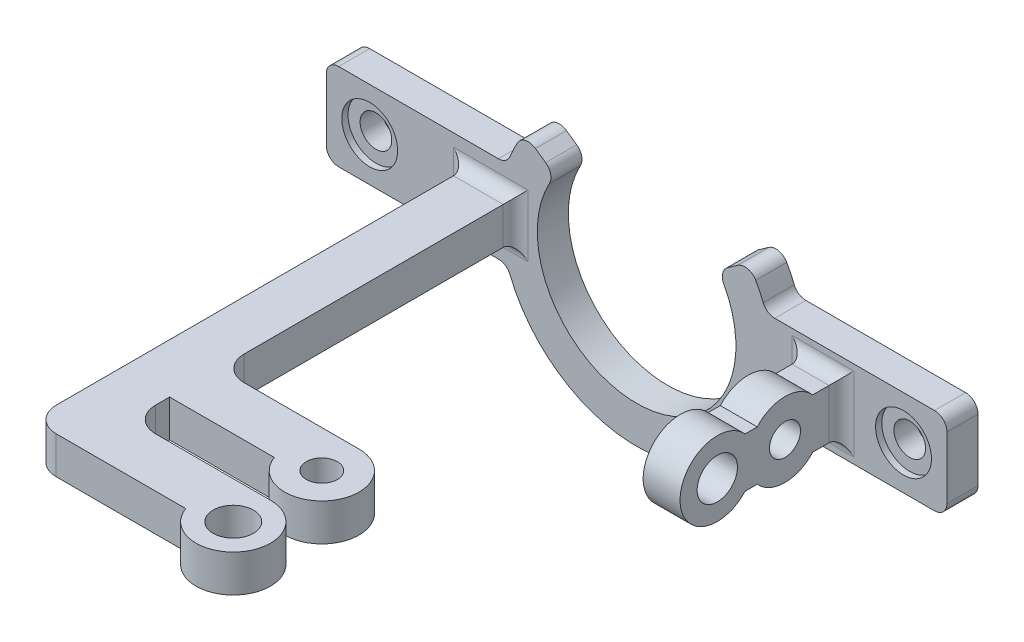
from build123d import *

# Parameters (mm, degrees)
SKETCH1_R                = 2.55
BOSS_EXTRUDE1_DEPTH      = 5
SKETCH4_R                = 4.5
CUT_EXTRUDE2_DEPTH       = 1
SKETCH6_W                = 5.947651005
SKETCH6_H                = 20
BOSS_EXTRUDE2_DEPTH      = 4
BOSS_EXTRUDE2_DEPTH_BACK = 4
SKETCH11_R               = 4.5
CUT_EXTRUDE3_DEPTH       = 0.5
SKETCH16_R               = 3.25
SKETCH16_R_2             = 2.5
BOSS_EXTRUDE3_DEPTH      = 3
BOSS_EXTRUDE3_DEPTH_BACK = 3
FILLET3_R                = 2
BOSS_EXTRUDE4_DEPTH      = 5.947651
CUT_EXTRUDE5_REACH       = 85
SKETCH18_R               = 3.25
SKETCH18_R_2             = 2.5


with BuildPart() as part:
    # Sketch1 → Boss-Extrude1 (new body)
    with BuildSketch(Plane.XY):
        with BuildLine():
            Line((100, 25), (100, 20))
            ThreePointArc((100, 20), (99.414213562, 18.585786438), (98, 18))
            Line((98, 18), (72.248595461, 18))
            ThreePointArc((72.248595461, 18), (71.130561473, 17.658312395), (70.39454584, 16.75))
            ThreePointArc((70.39454584, 16.75), (50, 3), (29.60545416, 16.75))
            ThreePointArc((29.60545416, 16.75), (28.869438527, 17.658312395), (27.751404539, 18))
            Line((27.751404539, 18), (2, 18))
            ThreePointArc((2, 18), (0.585786438, 18.585786438), (0, 20))
            Line((0, 20), (0, 25))
            Line((0, 25), (0, 30))
            ThreePointArc((0, 30), (0.585786438, 31.414213562), (2, 32))
            Line((2, 32), (21.056240945, 32))
            Line((21.056240945, 32), (27.751404539, 32))
            ThreePointArc((27.751404539, 32), (28.869438527, 32.341687605), (29.60545416, 33.25))
            ThreePointArc((29.60545416, 33.25), (30.166752838, 34.520625347), (30.807119991, 35.753295167))
            ThreePointArc((30.807119991, 35.753295167), (32.106461975, 36.725482012), (33.699080137, 36.414026968))
            Line((33.699080137, 36.414026968), (35.34656276, 35.260447216))
            ThreePointArc((35.34656276, 35.260447216), (36.146649881, 34.078494315), (35.955031011, 32.664127224))
            ThreePointArc((35.955031011, 32.664127224), (50, 9), (64.044968989, 32.664127224))
            ThreePointArc((64.044968989, 32.664127224), (63.853350119, 34.078494315), (64.65343724, 35.260447216))
            Line((64.65343724, 35.260447216), (66.300919863, 36.414026968))
            ThreePointArc((66.300919863, 36.414026968), (67.893538025, 36.725482012), (69.192880009, 35.753295167))
            ThreePointArc((69.192880009, 35.753295167), (69.833247162, 34.520625347), (70.39454584, 33.25))
            ThreePointArc((70.39454584, 33.25), (71.130561473, 32.341687605), (72.248595461, 32))
            Line((72.248595461, 32), (78.943759055, 32))
            Line((78.943759055, 32), (98, 32))
            ThreePointArc((98, 32), (99.414213562, 31.414213562), (100, 30))
            Line((100, 30), (100, 25))
        make_face()
        with Locations((93, 25)):
            Circle(SKETCH1_R, mode=Mode.SUBTRACT)
        with Locations((7, 25)):
            Circle(SKETCH1_R, mode=Mode.SUBTRACT)
    extrude(amount=BOSS_EXTRUDE1_DEPTH)

    # Sketch4 → Cut-Extrude2 (cut)
    with BuildSketch(Plane.XY.offset(5)):
        with Locations((93, 25)):
            Circle(SKETCH4_R)
        with Locations((7, 25)):
            Circle(SKETCH4_R)
    extrude(amount=-CUT_EXTRUDE2_DEPTH, mode=Mode.SUBTRACT)

    # Sketch6 → Boss-Extrude2 (add, two sides)
    with BuildSketch(Plane(origin=(0, 25, 0), x_dir=(-1, 0, 0), z_dir=(0, -1, 0))) as boss_extrude2_sk:
        with Locations((-80.026174497, -15)):
            Rectangle(SKETCH6_W, SKETCH6_H)
    extrude(amount=BOSS_EXTRUDE2_DEPTH)
    extrude(boss_extrude2_sk.sketch, amount=-BOSS_EXTRUDE2_DEPTH_BACK)

    # Sketch11 → Cut-Extrude3 (cut)
    with BuildSketch(Plane(origin=(0, 0, 0), x_dir=(-1, 0, 0), z_dir=(0, 0, -1))):
        with Locations((-93, 25)):
            Circle(SKETCH11_R)
        with Locations((-7, 25)):
            Circle(SKETCH11_R)
    extrude(amount=-CUT_EXTRUDE3_DEPTH, mode=Mode.SUBTRACT)

    # Sketch16 → Boss-Extrude3 (add, two sides)
    with BuildSketch(Plane(origin=(0, 25, 0), x_dir=(-1, 0, 0), z_dir=(0, -1, 0))) as boss_extrude3_sk:
        with BuildLine():
            Line((-30.494270905, -5), (-22.494270905, -5))
            Line((-22.494270905, -5), (-22.494270905, -71))
            ThreePointArc((-22.494270905, -71), (-23.665843781, -73.828427125), (-26.494270905, -75))
            Line((-26.494270905, -75), (-30.494270905, -75))
            Line((-30.494270905, -75), (-47.361403242, -75))
            ThreePointArc((-47.361403242, -75), (-57.917236977, -76.464101615), (-53.018257491, -67))
            Line((-53.018257491, -67), (-34.494270905, -67))
            ThreePointArc((-34.494270905, -67), (-31.665843781, -65.828427125), (-30.494270905, -63))
            Line((-30.494270905, -63), (-30.494270905, -60.732138804))
            Line((-30.494270905, -60.732138804), (-47.361403242, -60.732138804))
            ThreePointArc((-47.361403242, -60.732138804), (-57.917236977, -62.196240419), (-53.018257491, -52.732138804))
            Line((-53.018257491, -52.732138804), (-34.494270905, -52.732138804))
            ThreePointArc((-34.494270905, -52.732138804), (-31.665843781, -51.560565928), (-30.494270905, -48.732138804))
            Line((-30.494270905, -48.732138804), (-30.494270905, -5))
        make_face()
        with Locations((-53.018257491, -73)):
            Circle(SKETCH16_R, mode=Mode.SUBTRACT)
        with Locations((-53.018257491, -58.732138804)):
            Circle(SKETCH16_R_2, mode=Mode.SUBTRACT)
    extrude(amount=BOSS_EXTRUDE3_DEPTH)
    extrude(boss_extrude3_sk.sketch, amount=-BOSS_EXTRUDE3_DEPTH_BACK)

    # Fillet3
    fillet3_edges = [part.edges().sort_by_distance(p)[0] for p in [
        (83, 25, 5),
        (80.026174498, 29, 5),
        (77.052348995, 25, 5),
        (80.026174498, 21, 5),
        (30.494270905, 25, 5),
        (26.494270905, 28, 5),
        (22.494270905, 25, 5),
        (26.494270905, 22, 5),
    ]]
    fillet(fillet3_edges, radius=FILLET3_R)

    # Sketch17 → Boss-Extrude4 (add)
    with BuildSketch(Plane(origin=(83, 0, 0), x_dir=(0, 0, -1), z_dir=(1, 0, 0))):
        with BuildLine():
            ThreePointArc((-19.547210182, 27.503414308), (-31, 25), (-19.547210182, 22.496585692))
            ThreePointArc((-19.547210182, 22.496585692), (-8.094420363, 25), (-19.547210182, 27.503414308))
        make_face()
    extrude(amount=-BOSS_EXTRUDE4_DEPTH)

    # Sketch18 → Cut-Extrude5 (cut, up to next)
    with BuildSketch(Plane(origin=(83, 0, 0), x_dir=(0, 0, -1), z_dir=(1, 0, 0)), mode=Mode.PRIVATE) as cut_extrude5_sk1:
        with Locations((-25, 25)):
            Circle(SKETCH18_R)
    cut_extrude5_tool1 = extrude(cut_extrude5_sk1.sketch, amount=-CUT_EXTRUDE5_REACH, mode=Mode.PRIVATE) & part.part
    add(cut_extrude5_tool1.solids().sort_by_distance((83, 25, 25))[0], mode=Mode.SUBTRACT)
    # Sketch18 → Cut-Extrude5 (cut, up to next)
    with BuildSketch(Plane(origin=(83, 0, 0), x_dir=(0, 0, -1), z_dir=(1, 0, 0)), mode=Mode.PRIVATE) as cut_extrude5_sk2:
        with Locations((-14.094420363, 25)):
            Circle(SKETCH18_R_2)
    cut_extrude5_tool2 = extrude(cut_extrude5_sk2.sketch, amount=-CUT_EXTRUDE5_REACH, mode=Mode.PRIVATE) & part.part
    add(cut_extrude5_tool2.solids().sort_by_distance((83, 25, 14.09442))[0], mode=Mode.SUBTRACT)


solid = part.part
